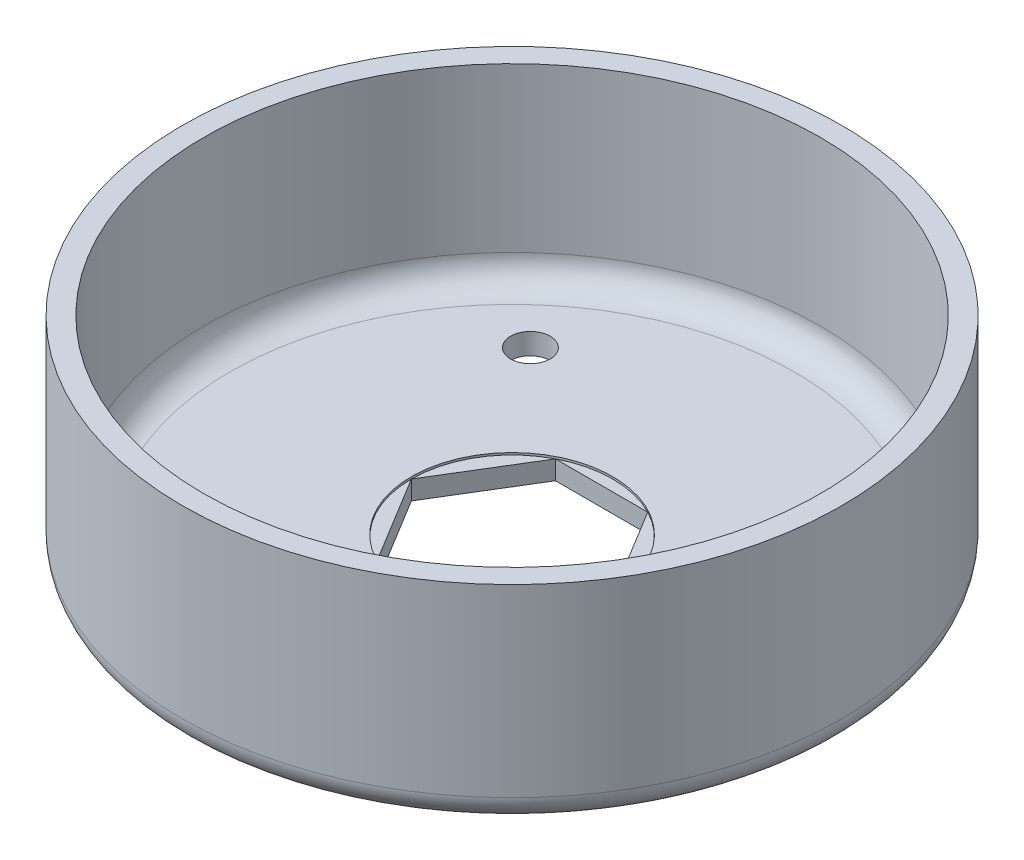
from build123d import *

# Parameters (mm, degrees)
SKETCH1_R           = 39.6875
BOSS_EXTRUDE1_DEPTH = 25.4
SHELL1_T            = -2.54
CUT_EXTRUDE1_DEPTH  = 62.60645512
SKETCH4_R           = 12.124567064
CUT_EXTRUDE2_DEPTH  = 0.254
FILLET1_R           = 3.175
SKETCH5_R           = 2.38125
CUT_EXTRUDE3_DEPTH  = 62.606455185
FILLET2_R           = 3.175


with BuildPart() as part:
    # Sketch1 → Boss-Extrude1 (new body)
    with BuildSketch(Plane(origin=(0, 0, 0), x_dir=(1, 0, 0), z_dir=(0, 1, 0))):
        with Locations(Location((0, 0, 0), (0, 0, 270))):
            Circle(SKETCH1_R)
    extrude(amount=BOSS_EXTRUDE1_DEPTH)

    # Shell1
    shell1_openings = [part.faces().sort_by_distance(p)[0] for p in [
        (0, 25.4, 0),
    ]]
    offset(amount=SHELL1_T, openings=shell1_openings, kind=Kind.INTERSECTION)

    # Sketch2 → Cut-Extrude1 (cut, through all)
    with BuildSketch(Plane(origin=(0, 25.4, 0), x_dir=(1, 0, 0), z_dir=(0, 1, 0))):
        Polygon((-5.55625, 10.776512071), (5.55625, 10.776512071), (12.124567064, 0), (5.55625, -10.776512071), (-5.55625, -10.776512071), (-12.124567064, 0), align=None)
    extrude(amount=-CUT_EXTRUDE1_DEPTH, mode=Mode.SUBTRACT)

    # Sketch4 → Cut-Extrude2 (cut)
    with BuildSketch(Plane(origin=(0, 2.54, 0), x_dir=(1, 0, 0), z_dir=(0, 1, 0))):
        with Locations(Location((0, 0, 0), (0, 0, 270))):
            Circle(SKETCH4_R)
    extrude(amount=-CUT_EXTRUDE2_DEPTH, mode=Mode.SUBTRACT)

    # Fillet1
    fillet1_edges = [part.edges().sort_by_distance(p)[0] for p in [
        (0, 0, -39.6875),
    ]]
    fillet(fillet1_edges, radius=FILLET1_R)

    # Sketch5 → Cut-Extrude3 (cut, through all)
    with BuildSketch(Plane.XZ):
        with Locations(Location((19.866785326, 20.619012071, 0), (0, 0, 270))):
            Circle(SKETCH5_R)
        with Locations(Location((-18.413118107, 20.619012071, 0), (0, 0, 270))):
            Circle(SKETCH5_R)
        with Locations(Location((-18.413118107, -20.619012071, 0), (0, 0, 270))):
            Circle(SKETCH5_R)
        with Locations(Location((19.866785326, -17.126512071, 0), (0, 0, 270))):
            Circle(SKETCH5_R)
    extrude(amount=-CUT_EXTRUDE3_DEPTH, mode=Mode.SUBTRACT)

    # Fillet2
    fillet2_edges = [part.edges().sort_by_distance(p)[0] for p in [
        (0, 2.54, -37.1475),
    ]]
    fillet(fillet2_edges, radius=FILLET2_R)


solid = part.part
